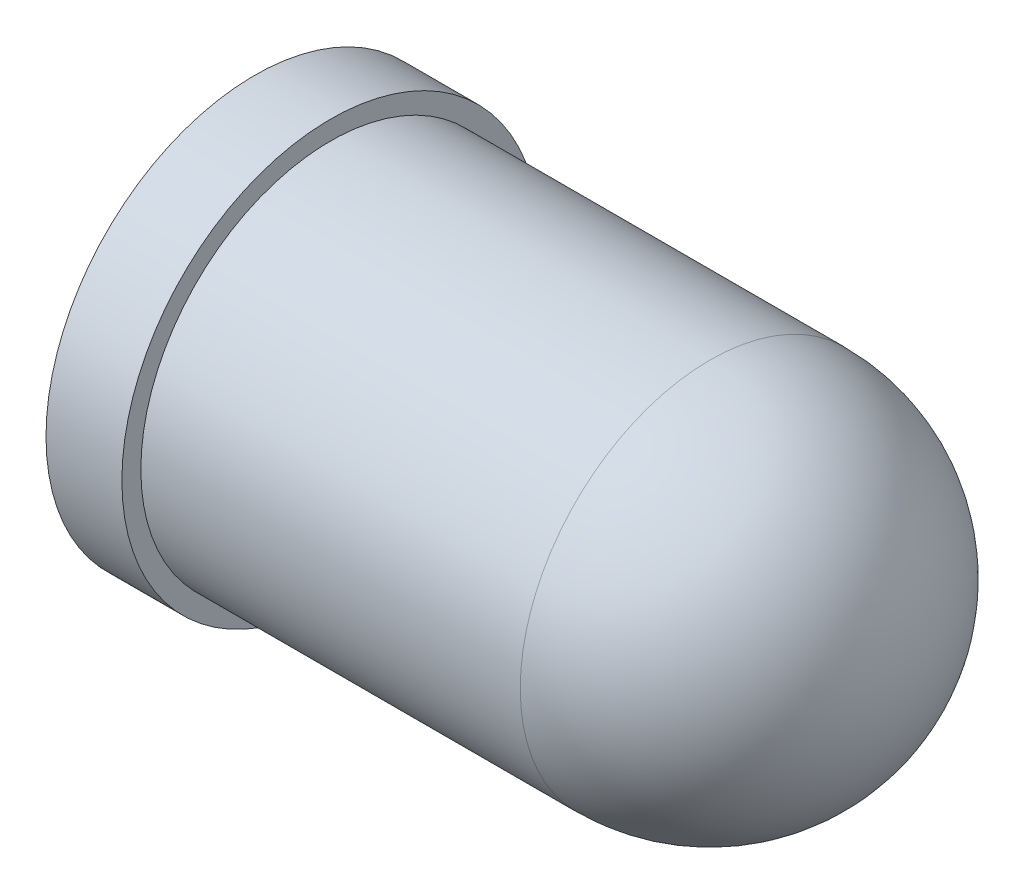
from build123d import *


with BuildPart() as part:
    # Sketch1 → Revolve1 (revolve)
    with BuildSketch(Plane.XY):
        with BuildLine():
            Line((0, 2.5), (-5, 2.5))
            Line((-5, 2.5), (-5, 2.75))
            Line((-5, 2.75), (-6, 2.75))
            Line((-6, 2.75), (-6, 0))
            Line((-6, 0), (2.5, 0))
            ThreePointArc((2.5, 0), (1.767766953, 1.767766953), (0, 2.5))
        make_face()
    revolve(axis=Axis((-6, 0, 0), (1, 0, 0)))


solid = part.part
